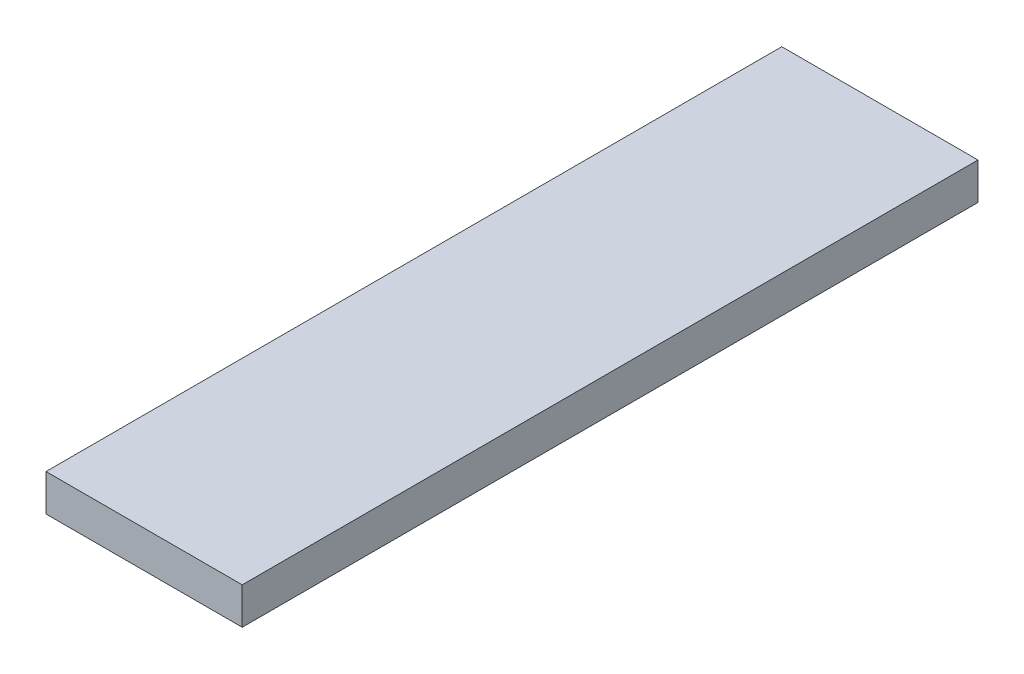
from build123d import *

# Parameters (mm, degrees)
SKETCH_1_W      = 16
SKETCH_1_H      = 60
EXTRUDE_1_DEPTH = 3


with BuildPart() as part:
    # 草图1 → 凸台-拉伸1 (new body)
    with BuildSketch(Plane(origin=(0, 0, 0), x_dir=(1, 0, 0), z_dir=(0, 1, 0))):
        Rectangle(SKETCH_1_W, SKETCH_1_H)
    extrude(amount=EXTRUDE_1_DEPTH)


solid = part.part
